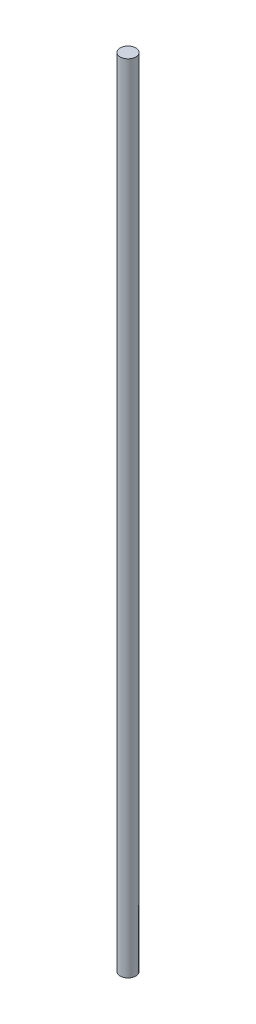
from build123d import *

# Parameters (mm, degrees)
SKETCH1_R           = 5
BOSS_EXTRUDE1_DEPTH = 506.5


with BuildPart() as part:
    # Sketch1 → Boss-Extrude1 (new body)
    with BuildSketch(Plane(origin=(0, 0, 0), x_dir=(1, 0, 0), z_dir=(0, 1, 0))):
        Circle(SKETCH1_R)
    extrude(amount=BOSS_EXTRUDE1_DEPTH)


solid = part.part
